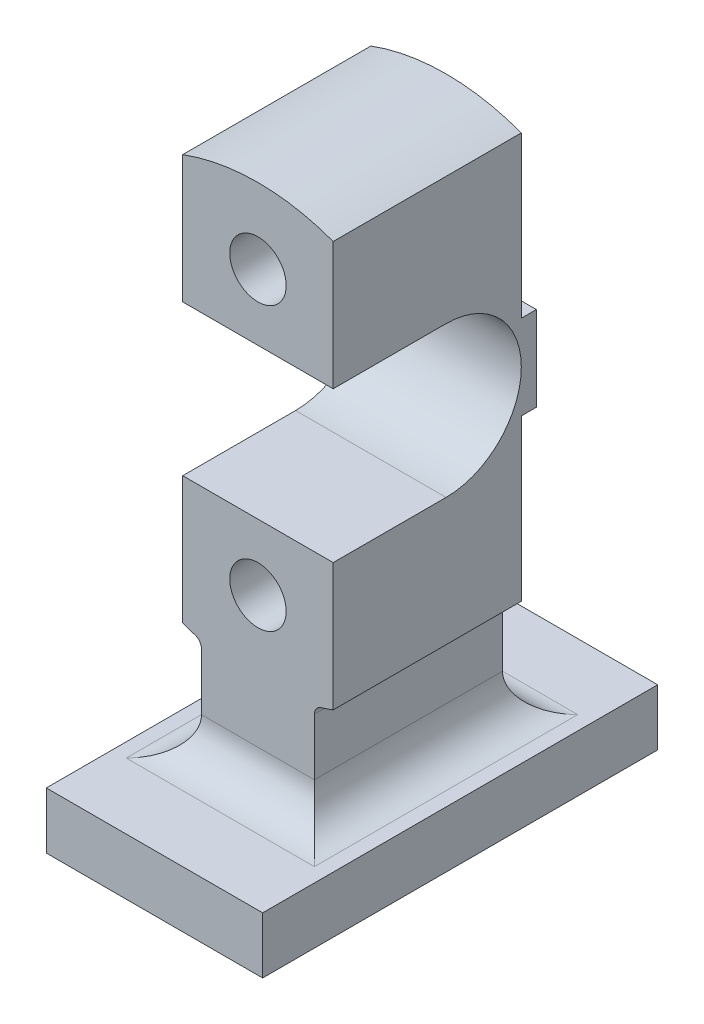
from build123d import *

# Parameters (mm, degrees)
SKETCH1_R           = 15
BOSS_EXTRUDE2_DEPTH = 100
SKETCH3_W           = 115
SKETCH3_H           = 30
BOSS_EXTRUDE3_DEPTH = 160
SKETCH4_W           = 5
SKETCH4_H           = 30
SKETCH4_W_2         = 105
CUT_EXTRUDE1_DEPTH  = 320
FILLET5_R           = 20
FILLET6_R           = 20
SKETCH6_W           = 8
SKETCH6_H           = 45
BOSS_EXTRUDE4_DEPTH = 80
CUT_EXTRUDE2_DEPTH  = 80


with BuildPart() as part:
    # Sketch1 → Boss-Extrude2 (new body)
    with BuildSketch(Plane.XY):
        with BuildLine():
            ThreePointArc((33.541666667, -109.999802714), (36.786992802, -108.957409847), (40, -107.819293264))
            Line((40, -107.819293264), (40, 107.819293264))
            ThreePointArc((40, 107.819293264), (0, 115), (-40, 107.819293264))
            Line((-40, 107.819293264), (-40, -107.819293264))
            ThreePointArc((-40, -107.819293264), (-36.786992802, -108.957409847), (-33.541666667, -109.999802714))
            ThreePointArc((-33.541666667, -109.999802714), (-30.981812183, -111.806807654), (-30, -114.782402832))
            Line((-30, -114.782402832), (-30, -145))
            ThreePointArc((-30, -145), (-35.857864376, -159.142135624), (-50, -165))
            Line((-50, -165), (-30, -165))
            Line((-30, -165), (30, -165))
            Line((30, -165), (50, -165))
            ThreePointArc((50, -165), (35.857864376, -159.142135624), (30, -145))
            Line((30, -145), (30, -114.782402832))
            ThreePointArc((30, -114.782402832), (30.981812183, -111.806807654), (33.541666667, -109.999802714))
        make_face()
        with Locations((0, -75)):
            Circle(SKETCH1_R, mode=Mode.SUBTRACT)
        with Locations((0, 75)):
            Circle(SKETCH1_R, mode=Mode.SUBTRACT)
    extrude(amount=BOSS_EXTRUDE2_DEPTH)

    # Sketch3 → Boss-Extrude3 (add, symmetric)
    with BuildSketch(Plane.XY):
        with Locations((0, -180)):
            Rectangle(SKETCH3_W, SKETCH3_H)
    extrude(amount=BOSS_EXTRUDE3_DEPTH, both=True)

    # Sketch4 → Cut-Extrude1 (cut)
    with BuildSketch(Plane(origin=(57.5, 0, 0), x_dir=(0, 0, -1), z_dir=(1, 0, 0))):
        with Locations((-157.5, -180)):
            Rectangle(SKETCH4_W, SKETCH4_H)
        with Locations((107.5, -180)):
            Rectangle(SKETCH4_W_2, SKETCH4_H)
    extrude(amount=-CUT_EXTRUDE1_DEPTH, mode=Mode.SUBTRACT)

    # Fillet5
    fillet5_edges = [part.edges().sort_by_distance(p)[0] for p in [
        (0, -165, 100),
    ]]
    fillet(fillet5_edges, radius=FILLET5_R)

    # Fillet6
    fillet6_edges = [part.edges().sort_by_distance(p)[0] for p in [
        (0, -165, 0),
    ]]
    fillet(fillet6_edges, radius=FILLET6_R)

    # Sketch6 → Boss-Extrude4 (add)
    with BuildSketch(Plane(origin=(40, 0, 0), x_dir=(0, 0, -1), z_dir=(1, 0, 0))):
        with Locations((4, 0)):
            Rectangle(SKETCH6_W, SKETCH6_H)
    extrude(amount=-BOSS_EXTRUDE4_DEPTH)

    # Sketch7 → Cut-Extrude2 (cut)
    with BuildSketch(Plane(origin=(40, 0, 0), x_dir=(0, 0, -1), z_dir=(1, 0, 0))):
        with BuildLine():
            Line((-40, 40), (-100, 40))
            Line((-100, 40), (-100, -40))
            Line((-100, -40), (-40, -40))
            ThreePointArc((-40, -40), (0, 0), (-40, 40))
        make_face()
    extrude(amount=-CUT_EXTRUDE2_DEPTH, mode=Mode.SUBTRACT)


solid = part.part
